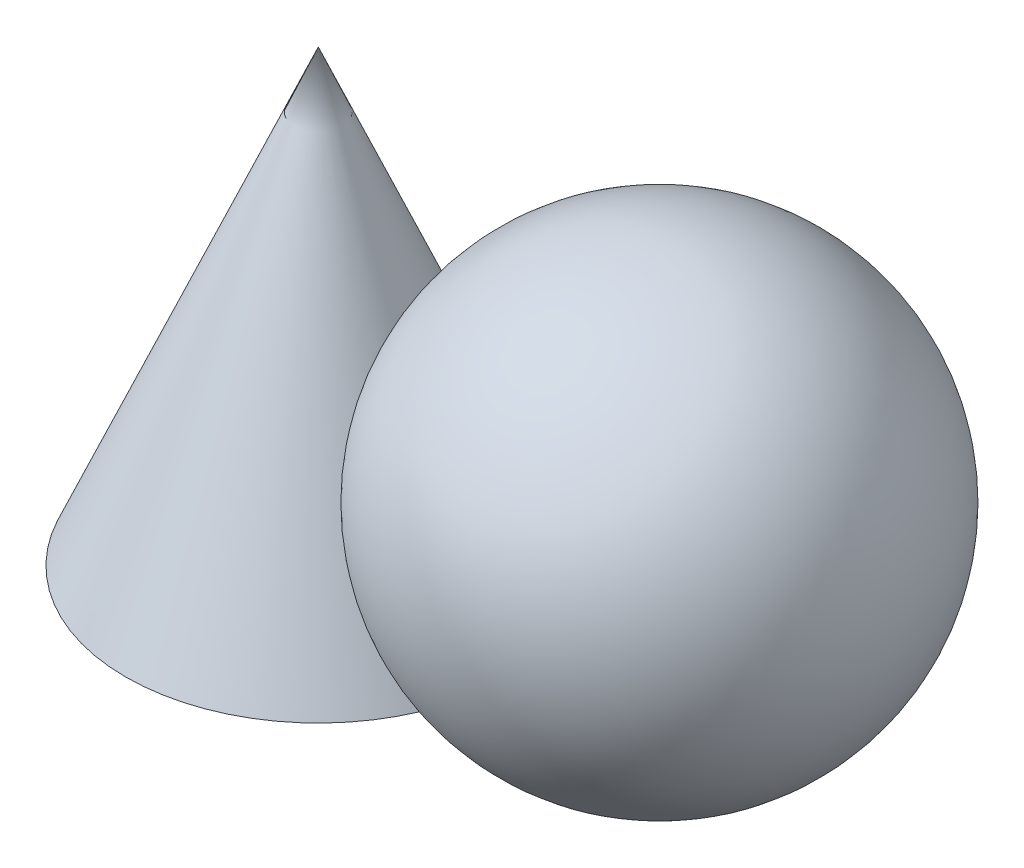
from build123d import *

# Parameters (mm, degrees)
SKETCH1_R = 30


with BuildPart() as part:
    # Sketch1 → Loft1 section 0
    with BuildSketch(Plane(origin=(0, 0, 0), x_dir=(1, 0, 0), z_dir=(0, 1, 0)), mode=Mode.PRIVATE) as loft1_s0:
        Circle(SKETCH1_R)
    loft([Vertex(0, 70, 0), loft1_s0.sketch])

    # Sketch5 → Revolve2 (revolve)
    with BuildSketch(Plane.XY):
        with BuildLine():
            Line((53.137340566, 70.181364697), (53.137340566, 0))
            ThreePointArc((53.137340566, 0), (18.046658217, 35.090682349), (53.137340566, 70.181364697))
        make_face()
    revolve(axis=Axis((53.137340566, 70.181364697, 0), (0, -1, 0)))


solid = part.part
